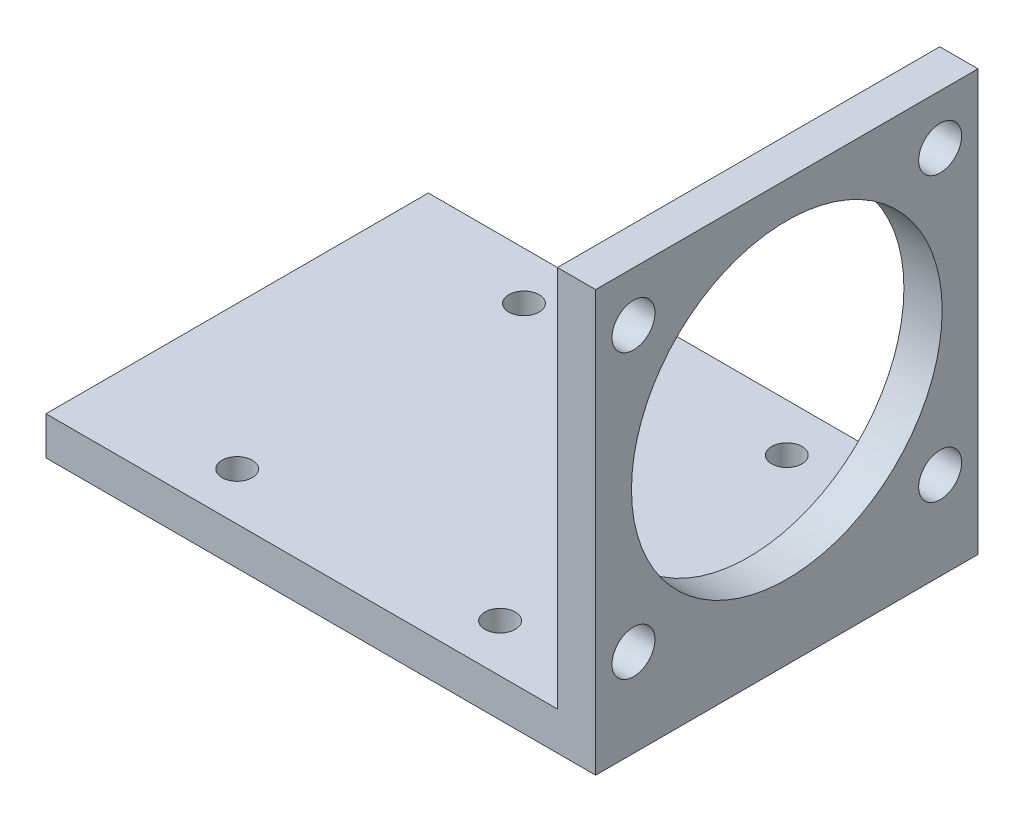
from build123d import *

# Parameters (mm, degrees)
CROQUIS1_W              = 57.5
CROQUIS1_H              = 40
SALIENTE_EXTRUIR1_DEPTH = 4
CROQUIS3_W              = 4
CROQUIS3_H              = 40
SALIENTE_EXTRUIR3_DEPTH = 40
CORTAR_EXTRUIR1_REACH   = 74.099
CROQUIS5_R              = 2.25
CORTAR_EXTRUIR2_REACH   = 74.099
CROQUIS7_R              = 16.25
CORTAR_EXTRUIR3_REACH   = 58.237
CROQUIS8_R              = 1.585


with BuildPart() as part:
    # Croquis1 → Saliente-Extruir1 (new body)
    with BuildSketch(Plane(origin=(0, 0, 0), x_dir=(1, 0, 0), z_dir=(0, 1, 0))):
        Rectangle(CROQUIS1_W, CROQUIS1_H)
    extrude(amount=SALIENTE_EXTRUIR1_DEPTH)

    # Croquis3 → Saliente-Extruir3 (add)
    with BuildSketch(Plane(origin=(0, 4, 0), x_dir=(1, 0, 0), z_dir=(0, 1, 0))):
        with Locations((26.75, 0)):
            Rectangle(CROQUIS3_W, CROQUIS3_H)
    extrude(amount=SALIENTE_EXTRUIR3_DEPTH)

    # Croquis5 → Cortar-Extruir1 (cut, up to next)
    with BuildSketch(Plane.ZY.offset(-24.75), mode=Mode.PRIVATE) as cortar_extruir1_sk1:
        with Locations((-16.04, 38.8)):
            Circle(CROQUIS5_R)
    cortar_extruir1_tool1 = extrude(cortar_extruir1_sk1.sketch, amount=-CORTAR_EXTRUIR1_REACH, mode=Mode.PRIVATE) & part.part
    # Croquis5 → Cortar-Extruir1 (cut, up to next)
    with BuildSketch(Plane.ZY.offset(-24.75), mode=Mode.PRIVATE) as cortar_extruir1_sk2:
        with Locations((16.04, 38.8)):
            Circle(CROQUIS5_R)
    cortar_extruir1_tool2 = extrude(cortar_extruir1_sk2.sketch, amount=-CORTAR_EXTRUIR1_REACH, mode=Mode.PRIVATE) & part.part
    # Croquis5 → Cortar-Extruir1 (cut, up to next)
    with BuildSketch(Plane.ZY.offset(-24.75), mode=Mode.PRIVATE) as cortar_extruir1_sk3:
        with Locations((16.04, 9.2)):
            Circle(CROQUIS5_R)
    cortar_extruir1_tool3 = extrude(cortar_extruir1_sk3.sketch, amount=-CORTAR_EXTRUIR1_REACH, mode=Mode.PRIVATE) & part.part
    # Croquis5 → Cortar-Extruir1 (cut, up to next)
    with BuildSketch(Plane.ZY.offset(-24.75), mode=Mode.PRIVATE) as cortar_extruir1_sk4:
        with Locations((-16.04, 9.2)):
            Circle(CROQUIS5_R)
    cortar_extruir1_tool4 = extrude(cortar_extruir1_sk4.sketch, amount=-CORTAR_EXTRUIR1_REACH, mode=Mode.PRIVATE) & part.part
    add(cortar_extruir1_tool1.solids().sort_by_distance((24.75, 38.8, -16.04))[0], mode=Mode.SUBTRACT)
    add(cortar_extruir1_tool2.solids().sort_by_distance((24.75, 38.8, 16.04))[0], mode=Mode.SUBTRACT)
    add(cortar_extruir1_tool3.solids().sort_by_distance((24.75, 9.2, 16.04))[0], mode=Mode.SUBTRACT)
    add(cortar_extruir1_tool4.solids().sort_by_distance((24.75, 9.2, -16.04))[0], mode=Mode.SUBTRACT)

    # Croquis7 → Cortar-Extruir2 (cut, up to next)
    with BuildSketch(Plane.ZY.offset(-24.75), mode=Mode.PRIVATE) as cortar_extruir2_sk1:
        with Locations((0, 24)):
            Circle(CROQUIS7_R)
    cortar_extruir2_tool1 = extrude(cortar_extruir2_sk1.sketch, amount=-CORTAR_EXTRUIR2_REACH, mode=Mode.PRIVATE) & part.part
    add(cortar_extruir2_tool1.solids().sort_by_distance((24.75, 24, 0))[0], mode=Mode.SUBTRACT)

    # Croquis8 → Cortar-Extruir3 (cut, up to next)
    with BuildSketch(Plane.XZ, mode=Mode.PRIVATE) as cortar_extruir3_sk1:
        with Locations((-13.75, 15)):
            Circle(CROQUIS8_R)
    cortar_extruir3_tool1 = extrude(cortar_extruir3_sk1.sketch, amount=-CORTAR_EXTRUIR3_REACH, mode=Mode.PRIVATE) & part.part
    # Croquis8 → Cortar-Extruir3 (cut, up to next)
    with BuildSketch(Plane.XZ, mode=Mode.PRIVATE) as cortar_extruir3_sk2:
        with Locations((13.75, 15)):
            Circle(CROQUIS8_R)
    cortar_extruir3_tool2 = extrude(cortar_extruir3_sk2.sketch, amount=-CORTAR_EXTRUIR3_REACH, mode=Mode.PRIVATE) & part.part
    cortar_extruir3_1 = cortar_extruir3_tool1.solids().sort_by_distance((-13.75, 0, 15))[0]
    add(cortar_extruir3_1, mode=Mode.SUBTRACT)
    cortar_extruir3_2 = cortar_extruir3_tool2.solids().sort_by_distance((13.75, 0, 15))[0]
    add(cortar_extruir3_2, mode=Mode.SUBTRACT)
    cortar_extruir3 = cortar_extruir3_1 + cortar_extruir3_2  # Cortar-Extruir3 as one shape, for the pattern or mirror that repeats it

    # Simetría1: Cortar-Extruir3 across plane
    add(cortar_extruir3.mirror(Plane.XY), mode=Mode.SUBTRACT)


solid = part.part
